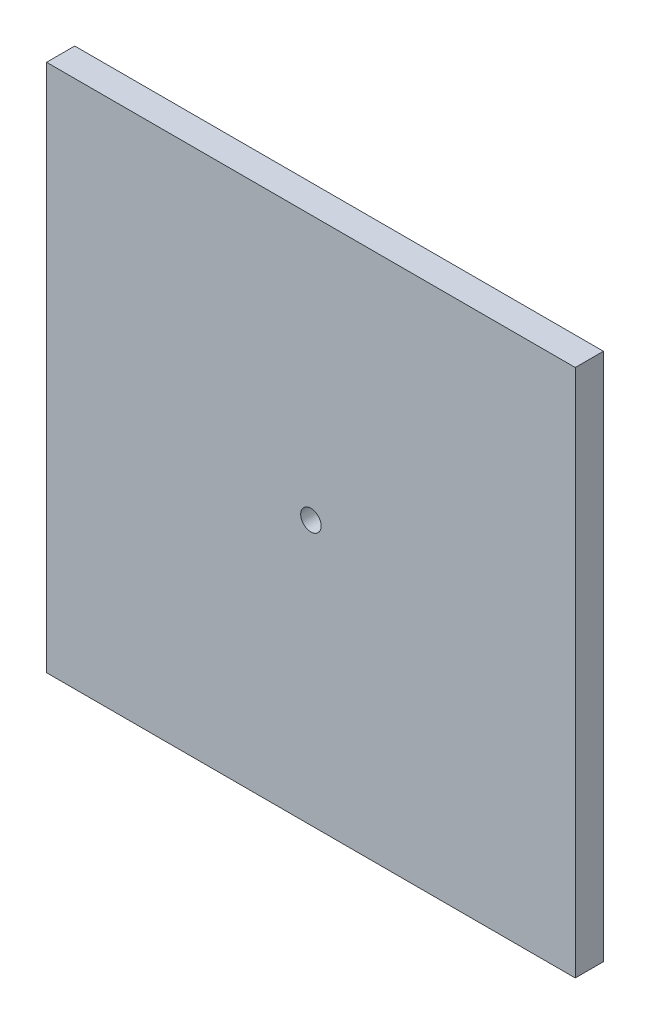
from build123d import *

# Parameters (mm, degrees)
SKETCH1_W           = 163.957
SKETCH1_H           = 163.957
SKETCH1_R           = 3.175
BOSS_EXTRUDE1_DEPTH = 8.73125
SKETCH1_5_R         = 3.175
BOSS_EXTRUDE4_DEPTH = 9.398


with BuildPart() as part:
    # Sketch1 → Boss-Extrude1 (new body)
    with BuildSketch(Plane.XY):
        Rectangle(SKETCH1_W, SKETCH1_H)
        Circle(SKETCH1_R, mode=Mode.SUBTRACT)
    extrude(amount=BOSS_EXTRUDE1_DEPTH)

    # Sketch1_5 → Boss-Extrude4 (add)
    with BuildSketch(Plane.XY):
        with Locations((-69.2785, 69.2785)):
            Circle(SKETCH1_5_R)
        with Locations((69.2785, 69.2785)):
            Circle(SKETCH1_5_R)
        with Locations((69.2785, -69.2785)):
            Circle(SKETCH1_5_R)
        with Locations((-69.2785, -69.2785)):
            Circle(SKETCH1_5_R)
    extrude(amount=-BOSS_EXTRUDE4_DEPTH)


solid = part.part
